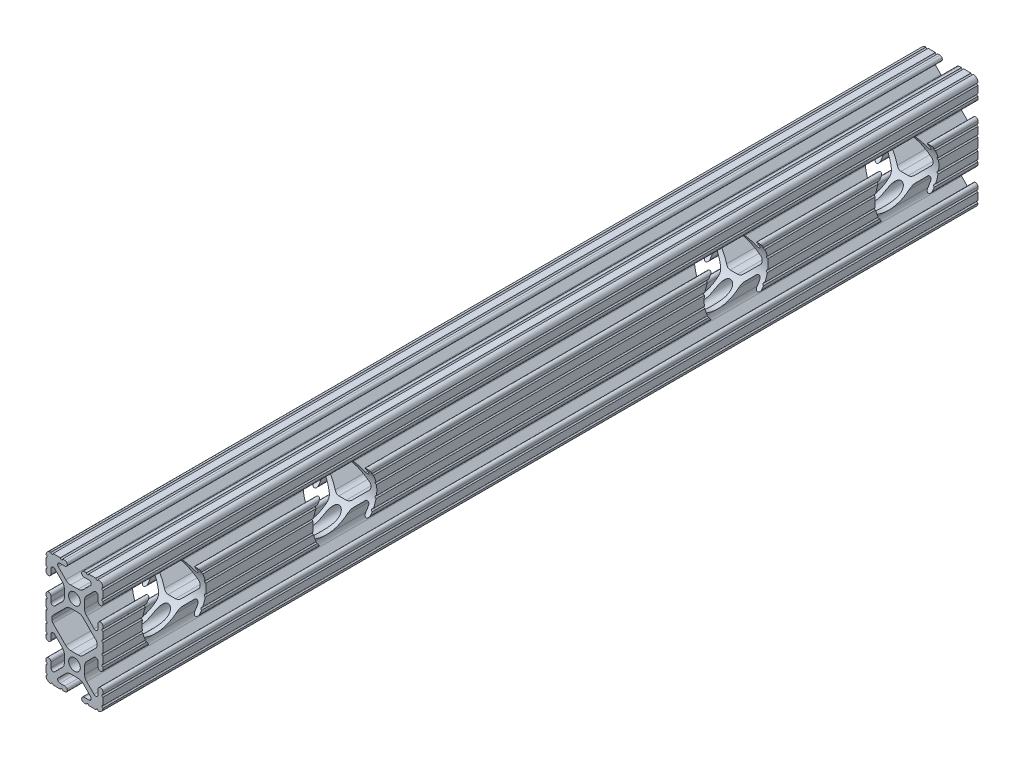
from build123d import *

# Parameters (mm, degrees)
SKETCH1_R           = 2.6035
BOSS_EXTRUDE1_DEPTH = 390.5504
CUT_EXTRUDE1_START  = -26.400038486
SKETCH2_R           = 14.2875
CUT_EXTRUDE1_DEPTH  = 27.400076971


with BuildPart() as part:
    # Sketch1 → Boss-Extrude1 (new body)
    with BuildSketch(Plane(origin=(0, 0, -889), x_dir=(-1, 0, 0), z_dir=(0, 0, -1))):
        with BuildLine():
            Line((9.5504, 38.1), (6.3246, 38.1))
            ThreePointArc((6.3246, 38.1), (5.8166, 37.592), (5.3086, 38.1))
            Line((5.3086, 38.1), (4.302307889, 38.1))
            ThreePointArc((4.302307889, 38.1), (3.197407889, 36.9951), (4.302307889, 35.8902))
            Line((4.302307889, 35.8902), (6.474794456, 35.8902))
            ThreePointArc((6.474794456, 35.8902), (7.413456061, 35.263006367), (7.193214945, 34.15577951))
            Line((7.193214945, 34.15577951), (3.875871405, 30.83843597))
            ThreePointArc((3.875871405, 30.83843597), (2.845827272, 30.150182484), (1.630807374, 29.9085))
            Line((1.630807374, 29.9085), (-1.630807374, 29.9085))
            ThreePointArc((-1.630807374, 29.9085), (-2.845827272, 30.150182484), (-3.875871405, 30.83843597))
            Line((-3.875871405, 30.83843597), (-7.193214945, 34.15577951))
            ThreePointArc((-7.193214945, 34.15577951), (-7.413456061, 35.263006367), (-6.474794456, 35.8902))
            Line((-6.474794456, 35.8902), (-4.302307889, 35.8902))
            ThreePointArc((-4.302307889, 35.8902), (-3.197407889, 36.9951), (-4.302307889, 38.1))
            Line((-4.302307889, 38.1), (-5.3086, 38.1))
            ThreePointArc((-5.3086, 38.1), (-5.8166, 37.592), (-6.3246, 38.1))
            Line((-6.3246, 38.1), (-9.5504, 38.1))
            ThreePointArc((-9.5504, 38.1), (-10.06475, 37.591960804), (-10.5791, 38.1))
            ThreePointArc((-10.5791, 38.1), (-12.082561002, 37.482561002), (-12.7, 35.9791))
            ThreePointArc((-12.7, 35.9791), (-12.191960804, 35.46475), (-12.7, 34.9504))
            Line((-12.7, 34.9504), (-12.7, 31.7246))
            ThreePointArc((-12.7, 31.7246), (-12.192, 31.2166), (-12.7, 30.7086))
            Line((-12.7, 30.7086), (-12.7, 29.702307889))
            ThreePointArc((-12.7, 29.702307889), (-11.5951, 28.597407889), (-10.4902, 29.702307889))
            Line((-10.4902, 29.702307889), (-10.4902, 31.874794456))
            ThreePointArc((-10.4902, 31.874794456), (-9.863006367, 32.813456061), (-8.75577951, 32.593214945))
            Line((-8.75577951, 32.593214945), (-5.43843597, 29.275871405))
            ThreePointArc((-5.43843597, 29.275871405), (-4.750182484, 28.245827272), (-4.5085, 27.030807374))
            Line((-4.5085, 27.030807374), (-4.5085, 23.769192626))
            ThreePointArc((-4.5085, 23.769192626), (-4.750182484, 22.554172728), (-5.43843597, 21.524128595))
            Line((-5.43843597, 21.524128595), (-8.75577951, 18.206785055))
            ThreePointArc((-8.75577951, 18.206785055), (-9.863006367, 17.986543939), (-10.4902, 18.925205544))
            Line((-10.4902, 18.925205544), (-10.4902, 21.097692082))
            ThreePointArc((-10.4902, 21.097692082), (-11.5951, 22.202592082), (-12.7, 21.097692082))
            Line((-12.7, 21.097692082), (-12.7, 20.0914))
            ThreePointArc((-12.7, 20.0914), (-12.192, 19.5834), (-12.7, 19.0754))
            Line((-12.7, 19.0754), (-12.7, 15.8496))
            ThreePointArc((-12.7, 15.8496), (-12.192, 15.3416), (-12.7, 14.8336))
            Line((-12.7, 14.8336), (-12.7, 10.5664))
            ThreePointArc((-12.7, 10.5664), (-12.192, 10.0584), (-12.7, 9.5504))
            Line((-12.7, 9.5504), (-12.7, 6.3246))
            ThreePointArc((-12.7, 6.3246), (-12.192, 5.8166), (-12.7, 5.3086))
            Line((-12.7, 5.3086), (-12.7, 4.302307889))
            ThreePointArc((-12.7, 4.302307889), (-11.5951, 3.197407889), (-10.4902, 4.302307889))
            Line((-10.4902, 4.302307889), (-10.4902, 6.474794456))
            ThreePointArc((-10.4902, 6.474794456), (-9.863006367, 7.413456061), (-8.75577951, 7.193214945))
            Line((-8.75577951, 7.193214945), (-5.43843597, 3.875871405))
            ThreePointArc((-5.43843597, 3.875871405), (-4.750182484, 2.845827272), (-4.5085, 1.630807374))
            Line((-4.5085, 1.630807374), (-4.5085, -1.630807374))
            ThreePointArc((-4.5085, -1.630807374), (-4.750182484, -2.845827272), (-5.43843597, -3.875871405))
            Line((-5.43843597, -3.875871405), (-8.75577951, -7.193214945))
            ThreePointArc((-8.75577951, -7.193214945), (-9.863006367, -7.413456061), (-10.4902, -6.474794456))
            Line((-10.4902, -6.474794456), (-10.4902, -4.302307889))
            ThreePointArc((-10.4902, -4.302307889), (-11.5951, -3.197407889), (-12.7, -4.302307889))
            Line((-12.7, -4.302307889), (-12.7, -5.3086))
            ThreePointArc((-12.7, -5.3086), (-12.192, -5.8166), (-12.7, -6.3246))
            Line((-12.7, -6.3246), (-12.7, -9.5504))
            ThreePointArc((-12.7, -9.5504), (-12.191960804, -10.06475), (-12.7, -10.5791))
            ThreePointArc((-12.7, -10.5791), (-12.082561002, -12.082561002), (-10.5791, -12.7))
            ThreePointArc((-10.5791, -12.7), (-10.06475, -12.191960804), (-9.5504, -12.7))
            Line((-9.5504, -12.7), (-6.3246, -12.7))
            ThreePointArc((-6.3246, -12.7), (-5.8166, -12.192), (-5.3086, -12.7))
            Line((-5.3086, -12.7), (-4.302307889, -12.7))
            ThreePointArc((-4.302307889, -12.7), (-3.197407889, -11.5951), (-4.302307889, -10.4902))
            Line((-4.302307889, -10.4902), (-6.474794456, -10.4902))
            ThreePointArc((-6.474794456, -10.4902), (-7.413456061, -9.863006367), (-7.193214945, -8.75577951))
            Line((-7.193214945, -8.75577951), (-3.875871405, -5.43843597))
            ThreePointArc((-3.875871405, -5.43843597), (-2.845827272, -4.750182484), (-1.630807374, -4.5085))
            Line((-1.630807374, -4.5085), (1.630807374, -4.5085))
            ThreePointArc((1.630807374, -4.5085), (2.845827272, -4.750182484), (3.875871405, -5.43843597))
            Line((3.875871405, -5.43843597), (7.193214945, -8.75577951))
            ThreePointArc((7.193214945, -8.75577951), (7.413456061, -9.863006367), (6.474794456, -10.4902))
            Line((6.474794456, -10.4902), (4.302307889, -10.4902))
            ThreePointArc((4.302307889, -10.4902), (3.197407889, -11.5951), (4.302307889, -12.7))
            Line((4.302307889, -12.7), (5.3086, -12.7))
            ThreePointArc((5.3086, -12.7), (5.8166, -12.192), (6.3246, -12.7))
            Line((6.3246, -12.7), (9.5504, -12.7))
            ThreePointArc((9.5504, -12.7), (10.06475, -12.191960804), (10.5791, -12.7))
            ThreePointArc((10.5791, -12.7), (12.082561002, -12.082561002), (12.7, -10.5791))
            ThreePointArc((12.7, -10.5791), (12.191960804, -10.06475), (12.7, -9.5504))
            Line((12.7, -9.5504), (12.7, -6.3246))
            ThreePointArc((12.7, -6.3246), (12.192, -5.8166), (12.7, -5.3086))
            Line((12.7, -5.3086), (12.7, -4.302307889))
            ThreePointArc((12.7, -4.302307889), (11.5951, -3.197407889), (10.4902, -4.302307889))
            Line((10.4902, -4.302307889), (10.4902, -6.474794456))
            ThreePointArc((10.4902, -6.474794456), (9.863006367, -7.413456061), (8.75577951, -7.193214945))
            Line((8.75577951, -7.193214945), (5.43843597, -3.875871405))
            ThreePointArc((5.43843597, -3.875871405), (4.750182484, -2.845827272), (4.5085, -1.630807374))
            Line((4.5085, -1.630807374), (4.5085, 1.630807374))
            ThreePointArc((4.5085, 1.630807374), (4.750182484, 2.845827272), (5.43843597, 3.875871405))
            Line((5.43843597, 3.875871405), (8.75577951, 7.193214945))
            ThreePointArc((8.75577951, 7.193214945), (9.863006367, 7.413456061), (10.4902, 6.474794456))
            Line((10.4902, 6.474794456), (10.4902, 4.302307889))
            ThreePointArc((10.4902, 4.302307889), (11.5951, 3.197407889), (12.7, 4.302307889))
            Line((12.7, 4.302307889), (12.7, 5.3086))
            ThreePointArc((12.7, 5.3086), (12.192, 5.8166), (12.7, 6.3246))
            Line((12.7, 6.3246), (12.7, 9.5504))
            ThreePointArc((12.7, 9.5504), (12.192, 10.0584), (12.7, 10.5664))
            Line((12.7, 10.5664), (12.7, 14.8336))
            ThreePointArc((12.7, 14.8336), (12.192, 15.3416), (12.7, 15.8496))
            Line((12.7, 15.8496), (12.7, 19.0754))
            ThreePointArc((12.7, 19.0754), (12.192, 19.5834), (12.7, 20.0914))
            Line((12.7, 20.0914), (12.7, 21.097692111))
            ThreePointArc((12.7, 21.097692111), (11.5951, 22.202592111), (10.4902, 21.097692111))
            Line((10.4902, 21.097692111), (10.4902, 18.925205544))
            ThreePointArc((10.4902, 18.925205544), (9.863006367, 17.986543939), (8.75577951, 18.206785055))
            Line((8.75577951, 18.206785055), (5.43843597, 21.524128595))
            ThreePointArc((5.43843597, 21.524128595), (4.750182484, 22.554172728), (4.5085, 23.769192626))
            Line((4.5085, 23.769192626), (4.5085, 27.030807374))
            ThreePointArc((4.5085, 27.030807374), (4.750182484, 28.245827272), (5.43843597, 29.275871405))
            Line((5.43843597, 29.275871405), (8.75577951, 32.593214945))
            ThreePointArc((8.75577951, 32.593214945), (9.863006367, 32.813456061), (10.4902, 31.874794456))
            Line((10.4902, 31.874794456), (10.4902, 29.702307889))
            ThreePointArc((10.4902, 29.702307889), (11.5951, 28.597407889), (12.7, 29.702307889))
            Line((12.7, 29.702307889), (12.7, 30.7086))
            ThreePointArc((12.7, 30.7086), (12.192, 31.2166), (12.7, 31.7246))
            Line((12.7, 31.7246), (12.7, 34.9504))
            ThreePointArc((12.7, 34.9504), (12.191960804, 35.46475), (12.7, 35.9791))
            ThreePointArc((12.7, 35.9791), (12.082561002, 37.482561002), (10.5791, 38.1))
            ThreePointArc((10.5791, 38.1), (10.06475, 37.591960804), (9.5504, 38.1))
        make_face()
        with Locations((0, 25.4)):
            Circle(SKETCH1_R, mode=Mode.SUBTRACT)
        Circle(SKETCH1_R, mode=Mode.SUBTRACT)
        with BuildLine():
            Line((10.033, 13.152131917), (10.033, 12.247868083))
            ThreePointArc((10.033, 12.247868083), (9.913125488, 11.645218214), (9.571751759, 11.134316324))
            Line((9.571751759, 11.134316324), (3.875871405, 5.43843597))
            ThreePointArc((3.875871405, 5.43843597), (2.845827272, 4.750182484), (1.630807374, 4.5085))
            Line((1.630807374, 4.5085), (-1.630807374, 4.5085))
            ThreePointArc((-1.630807374, 4.5085), (-2.845827272, 4.750182484), (-3.875871405, 5.43843597))
            Line((-3.875871405, 5.43843597), (-9.571751759, 11.134316324))
            ThreePointArc((-9.571751759, 11.134316324), (-9.913125488, 11.645218214), (-10.033, 12.247868083))
            Line((-10.033, 12.247868083), (-10.033, 13.152131917))
            ThreePointArc((-10.033, 13.152131917), (-9.913125488, 13.754781786), (-9.571751759, 14.265683676))
            Line((-9.571751759, 14.265683676), (-3.875871405, 19.96156403))
            ThreePointArc((-3.875871405, 19.96156403), (-2.845827272, 20.649817516), (-1.630807374, 20.8915))
            Line((-1.630807374, 20.8915), (1.630807374, 20.8915))
            ThreePointArc((1.630807374, 20.8915), (2.845827272, 20.649817516), (3.875871405, 19.96156403))
            Line((3.875871405, 19.96156403), (9.571751759, 14.265683676))
            ThreePointArc((9.571751759, 14.265683676), (9.913125488, 13.754781786), (10.033, 13.152131917))
        make_face(mode=Mode.SUBTRACT)
    extrude(amount=-BOSS_EXTRUDE1_DEPTH)

    # Sketch2 → Cut-Extrude1 (cut)
    with BuildSketch(Plane(origin=(12.7, 0, 0), x_dir=(0, 0, -1), z_dir=(1, 0, 0)).offset(CUT_EXTRUDE1_START)):
        with Locations((530.1996, 12.7)):
            Circle(SKETCH2_R)
        with Locations((606.3996, 12.7)):
            Circle(SKETCH2_R)
    cut_extrude1 = extrude(amount=CUT_EXTRUDE1_DEPTH, mode=Mode.SUBTRACT)

    # Mirror1: Cut-Extrude1 across plane
    add(cut_extrude1.mirror(Plane.XY.offset(-693.7248)), mode=Mode.SUBTRACT)


solid = part.part
